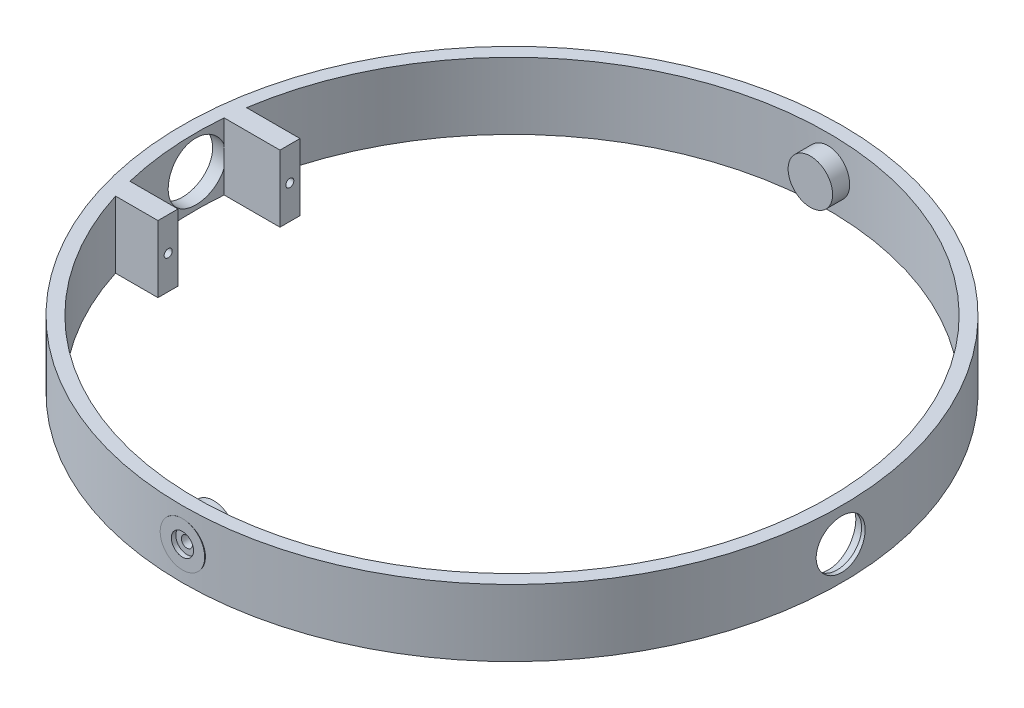
from build123d import *

# Parameters (mm, degrees)
SKETCH1_R               = 74
SKETCH1_R_2             = 71
BOSS_EXTRUDE1_DEPTH     = 15
SKETCH2_R               = 6.5
CUT_EXTRUDE1_DEPTH      = 73
CUT_EXTRUDE1_DEPTH_BACK = 75
SKETCH9_R               = 5.5
CUT_EXTRUDE6_DEPTH      = 75.0000001
BOSS_EXTRUDE2_START     = -6
SKETCH3_R               = 5
BOSS_EXTRUDE2_DEPTH     = 7
SKETCH4_W               = 10.783766206
SKETCH4_H               = 4.5
SKETCH4_W_2             = 12.537472389
BOSS_EXTRUDE3_DEPTH     = 15
SKETCH5_R               = 0.9
CUT_EXTRUDE2_DEPTH      = 8
SKETCH6_R               = 2.45
CUT_EXTRUDE3_DEPTH      = 4
SKETCH7_R               = 1.25
CUT_EXTRUDE4_DEPTH      = 4
SKETCH8_R               = 2.5
CUT_EXTRUDE5_DEPTH      = 4


with BuildPart() as part:
    # Sketch1 → Boss-Extrude1 (new body)
    with BuildSketch(Plane(origin=(0, 0, 0), x_dir=(1, 0, 0), z_dir=(0, 1, 0))):
        Circle(SKETCH1_R)
        Circle(SKETCH1_R_2, mode=Mode.SUBTRACT)
    extrude(amount=BOSS_EXTRUDE1_DEPTH)

    # Sketch2 → Cut-Extrude1 (cut, two sides)
    with BuildSketch(Plane(origin=(0, 0, 0), x_dir=(0, 0, -1), z_dir=(1, 0, 0))) as cut_extrude1_sk:
        with Locations((0, 7.5)):
            Circle(SKETCH2_R)
    extrude(amount=CUT_EXTRUDE1_DEPTH, mode=Mode.SUBTRACT)
    extrude(cut_extrude1_sk.sketch, amount=-CUT_EXTRUDE1_DEPTH_BACK, mode=Mode.SUBTRACT)

    # Sketch9 → Cut-Extrude6 (cut, through all)
    with BuildSketch(Plane(origin=(0, 0, 0), x_dir=(0, 0, -1), z_dir=(1, 0, 0))):
        with Locations((0, 7.5)):
            Circle(SKETCH9_R)
    extrude(amount=CUT_EXTRUDE6_DEPTH, mode=Mode.SUBTRACT)

    # Sketch3 → Boss-Extrude2 (add)
    with BuildSketch(Plane.XY.offset(73).offset(BOSS_EXTRUDE2_START)):
        with Locations((0, 7.5)):
            Circle(SKETCH3_R)
    boss_extrude2 = extrude(amount=BOSS_EXTRUDE2_DEPTH)

    # Mirror1: Boss-Extrude2 across plane
    add(boss_extrude2.mirror(Plane.XY))

    # Sketch4 → Boss-Extrude3 (add)
    with BuildSketch(Plane(origin=(0, 15, 0), x_dir=(1, 0, 0), z_dir=(0, 1, 0))):
        with Locations((-63.591883103, -19.05)):
            Rectangle(SKETCH4_W, SKETCH4_H)
        with Locations((-64.468736194, 8.35)):
            Rectangle(SKETCH4_W_2, SKETCH4_H)
    extrude(amount=-BOSS_EXTRUDE3_DEPTH)

    # Sketch5 → Cut-Extrude2 (cut)
    with BuildSketch(Plane(origin=(-58.2, 0, 0), x_dir=(0, 0, -1), z_dir=(1, 0, 0))):
        with Locations((8.3, 7.5)):
            Circle(SKETCH5_R)
        with Locations((-19, 7.5)):
            Circle(SKETCH5_R)
    extrude(amount=-CUT_EXTRUDE2_DEPTH, mode=Mode.SUBTRACT)

    # Sketch6 → Cut-Extrude3 (cut)
    with BuildSketch(Plane(origin=(0, 0, 67), x_dir=(-1, 0, 0), z_dir=(0, 0, -1))):
        with Locations((0, 7.5)):
            Circle(SKETCH6_R)
    extrude(amount=-CUT_EXTRUDE3_DEPTH, mode=Mode.SUBTRACT)

    # Sketch7 → Cut-Extrude4 (cut)
    with BuildSketch(Plane(origin=(0, 0, 71), x_dir=(-1, 0, 0), z_dir=(0, 0, -1))):
        with Locations((0, 7.5)):
            Circle(SKETCH7_R)
    extrude(amount=-CUT_EXTRUDE4_DEPTH, mode=Mode.SUBTRACT)

    # Sketch8 → Cut-Extrude5 (cut)
    with BuildSketch(Plane(origin=(0, 0, 73), x_dir=(-1, 0, 0), z_dir=(0, 0, -1))):
        with Locations((0, 7.5)):
            Circle(SKETCH8_R)
    extrude(amount=-CUT_EXTRUDE5_DEPTH, mode=Mode.SUBTRACT)


solid = part.part
